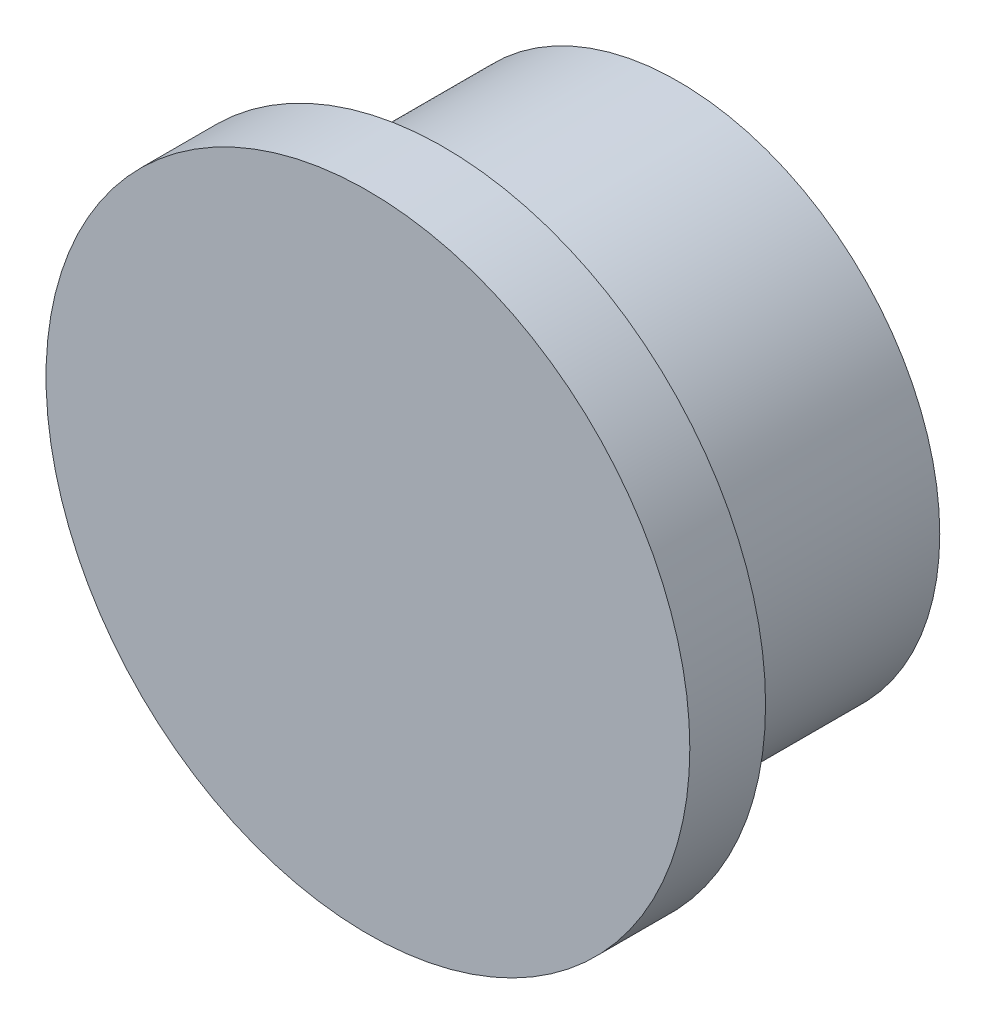
from build123d import *

# Parameters (mm, degrees)
CROQUIS1_R              = 3.45
CROQUIS1_R_2            = 2.45
SALIENTE_EXTRUIR1_DEPTH = 3.1
CROQUIS2_R              = 4.25
SALIENTE_EXTRUIR2_DEPTH = 1


with BuildPart() as part:
    # Croquis1 → Saliente-Extruir1 (new body)
    with BuildSketch(Plane.XY):
        Circle(CROQUIS1_R)
        Circle(CROQUIS1_R_2, mode=Mode.SUBTRACT)
    extrude(amount=SALIENTE_EXTRUIR1_DEPTH)

    # Croquis2 → Saliente-Extruir2 (add)
    with BuildSketch(Plane.XY.offset(3.1)):
        Circle(CROQUIS2_R)
    extrude(amount=SALIENTE_EXTRUIR2_DEPTH)


solid = part.part
